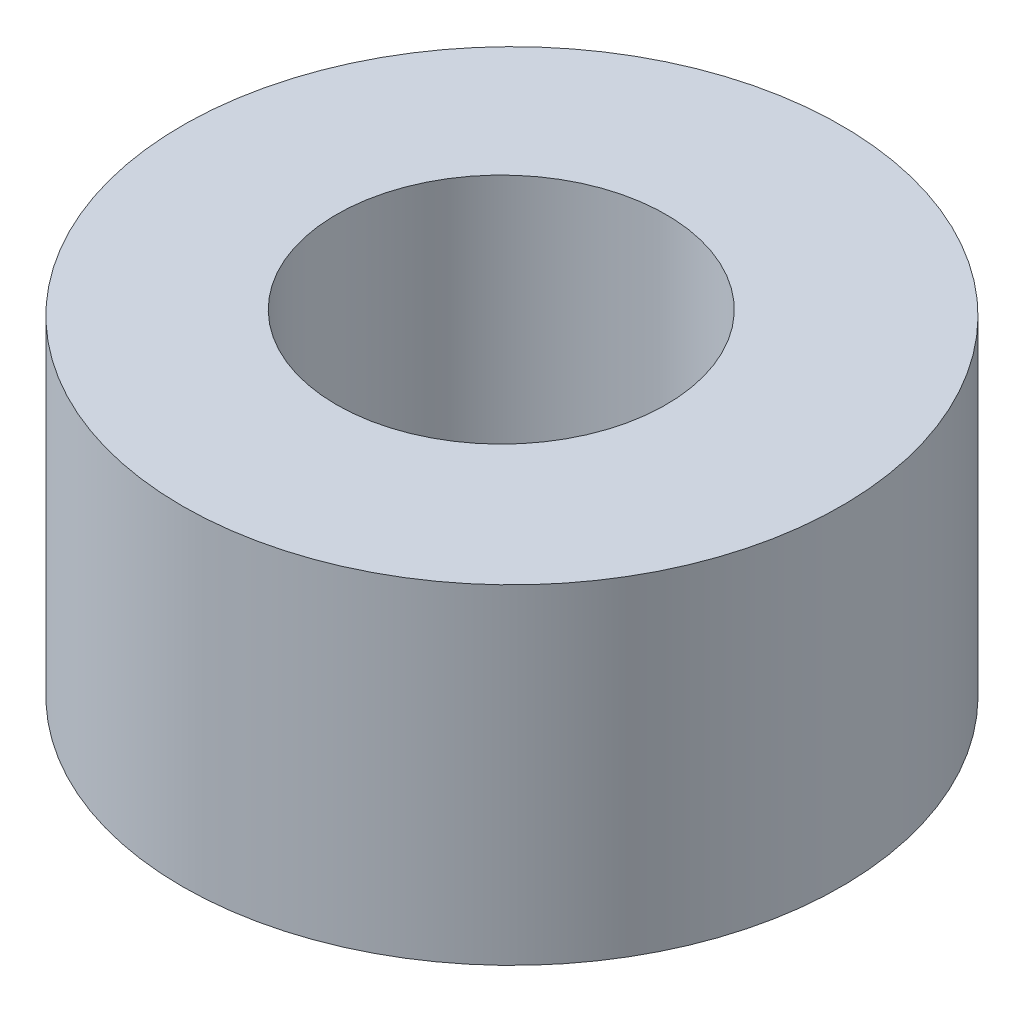
from build123d import *

# Parameters (mm, degrees)
SKETCH1_R           = 12.7
SKETCH1_R_2         = 6.35
BOSS_EXTRUDE1_DEPTH = 12.7


with BuildPart() as part:
    # Sketch1 → Boss-Extrude1 (new body)
    with BuildSketch(Plane(origin=(0, 0, 0), x_dir=(1, 0, 0), z_dir=(0, 1, 0))):
        Circle(SKETCH1_R)
        with Locations((-0.411574074, 0)):
            Circle(SKETCH1_R_2, mode=Mode.SUBTRACT)
    extrude(amount=BOSS_EXTRUDE1_DEPTH)


solid = part.part
